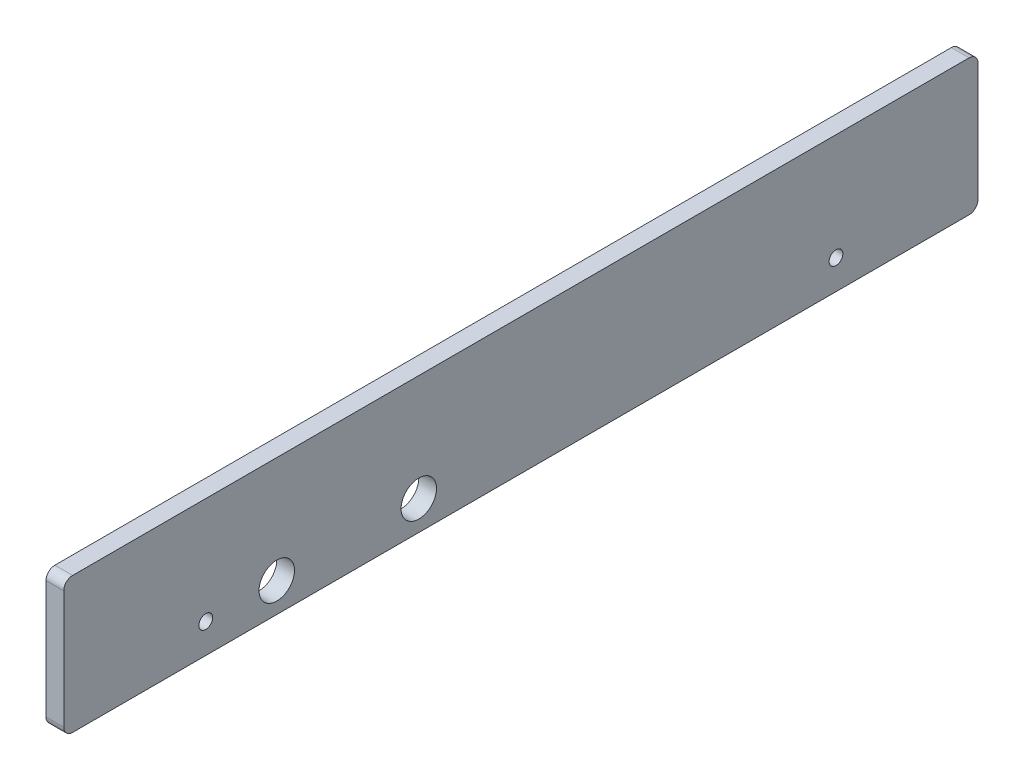
from build123d import *

# Parameters (mm, degrees)
SKETCH1_W           = 327.025
SKETCH1_H           = 48.63592
SKETCH1_R           = 2.45745
SKETCH1_R_2         = 6.35
BOSS_EXTRUDE1_DEPTH = 6.35
FILLET1_R           = 3.175


with BuildPart() as part:
    # Sketch1 → Boss-Extrude1 (new body)
    with BuildSketch(Plane(origin=(0, 0, 0), x_dir=(0, 0, -1), z_dir=(1, 0, 0))):
        with Locations((163.5125, 24.31796)):
            Rectangle(SKETCH1_W, SKETCH1_H)
        with Locations((50.8, 10.53592)):
            Circle(SKETCH1_R, mode=Mode.SUBTRACT)
        with Locations((276.225, 10.53592)):
            Circle(SKETCH1_R, mode=Mode.SUBTRACT)
        with Locations((76.2, 10.53592)):
            Circle(SKETCH1_R_2, mode=Mode.SUBTRACT)
        with Locations((127, 10.53592)):
            Circle(SKETCH1_R_2, mode=Mode.SUBTRACT)
    extrude(amount=BOSS_EXTRUDE1_DEPTH)

    # Fillet1
    fillet1_edges = [part.edges().sort_by_distance(p)[0] for p in [
        (3.175, 48.63592, 0),
        (3.175, 48.63592, -327.025),
        (3.175, 0, -327.025),
        (3.175, 0, 0),
    ]]
    fillet(fillet1_edges, radius=FILLET1_R)


solid = part.part
